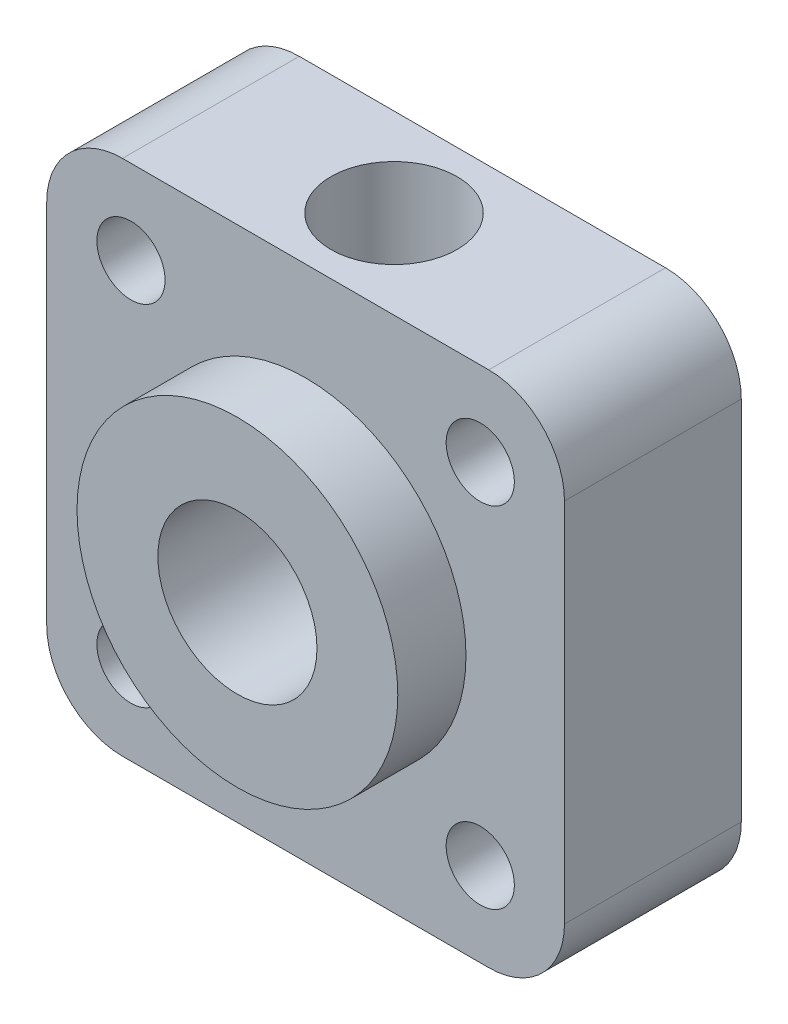
from build123d import *

# Parameters (mm, degrees)
CROQUIS1_W              = 20.5
CROQUIS1_H              = 20.5
SALIENTE_EXTRUIR1_DEPTH = 7
REDONDEO1_R             = 3
CROQUIS2_R              = 6.35
SALIENTE_EXTRUIR2_DEPTH = 2.7
CROQUIS3_R              = 3.15
CORTAR_EXTRUIR1_DEPTH   = 10.7
CROQUIS4_R              = 1.35
CORTAR_EXTRUIR2_DEPTH   = 8
CORTAR_EXTRUIR3_REACH   = 22.5
CROQUIS5_R              = 2.5


with BuildPart() as part:
    # Croquis1 → Saliente-Extruir1 (new body)
    with BuildSketch(Plane.XY):
        Rectangle(CROQUIS1_W, CROQUIS1_H)
    extrude(amount=SALIENTE_EXTRUIR1_DEPTH)

    # Redondeo1
    redondeo1_edges = [part.edges().sort_by_distance(p)[0] for p in [
        (10.25, -10.25, 3.5),
        (-10.25, -10.25, 3.5),
        (-10.25, 10.25, 3.5),
        (10.25, 10.25, 3.5),
    ]]
    fillet(redondeo1_edges, radius=REDONDEO1_R)

    # Croquis2 → Saliente-Extruir2 (add)
    with BuildSketch(Plane.XY.offset(7)):
        Circle(CROQUIS2_R)
    extrude(amount=SALIENTE_EXTRUIR2_DEPTH)

    # Croquis3 → Cortar-Extruir1 (cut, through all)
    with BuildSketch(Plane.XY.offset(9.7)):
        Circle(CROQUIS3_R)
    extrude(amount=-CORTAR_EXTRUIR1_DEPTH, mode=Mode.SUBTRACT)

    # Croquis4 → Cortar-Extruir2 (cut, through all)
    with BuildSketch(Plane.XY.offset(7)):
        with Locations((-6.91550432, 6.91550432)):
            Circle(CROQUIS4_R)
        with Locations((6.91550432, 6.91550432)):
            Circle(CROQUIS4_R)
        with Locations((6.91550432, -6.91550432)):
            Circle(CROQUIS4_R)
        with Locations((-6.91550432, -6.91550432)):
            Circle(CROQUIS4_R)
    extrude(amount=-CORTAR_EXTRUIR2_DEPTH, mode=Mode.SUBTRACT)

    # Croquis5 → Cortar-Extruir3 (cut, up to next)
    with BuildSketch(Plane(origin=(0, 10.25, 0), x_dir=(1, 0, 0), z_dir=(0, 1, 0)), mode=Mode.PRIVATE) as cortar_extruir3_sk1:
        with Locations((0, -3.5)):
            Circle(CROQUIS5_R)
    cortar_extruir3_tool1 = extrude(cortar_extruir3_sk1.sketch, amount=-CORTAR_EXTRUIR3_REACH, mode=Mode.PRIVATE) & part.part
    add(cortar_extruir3_tool1.solids().sort_by_distance((0, 10.25, 3.5))[0], mode=Mode.SUBTRACT)


solid = part.part
